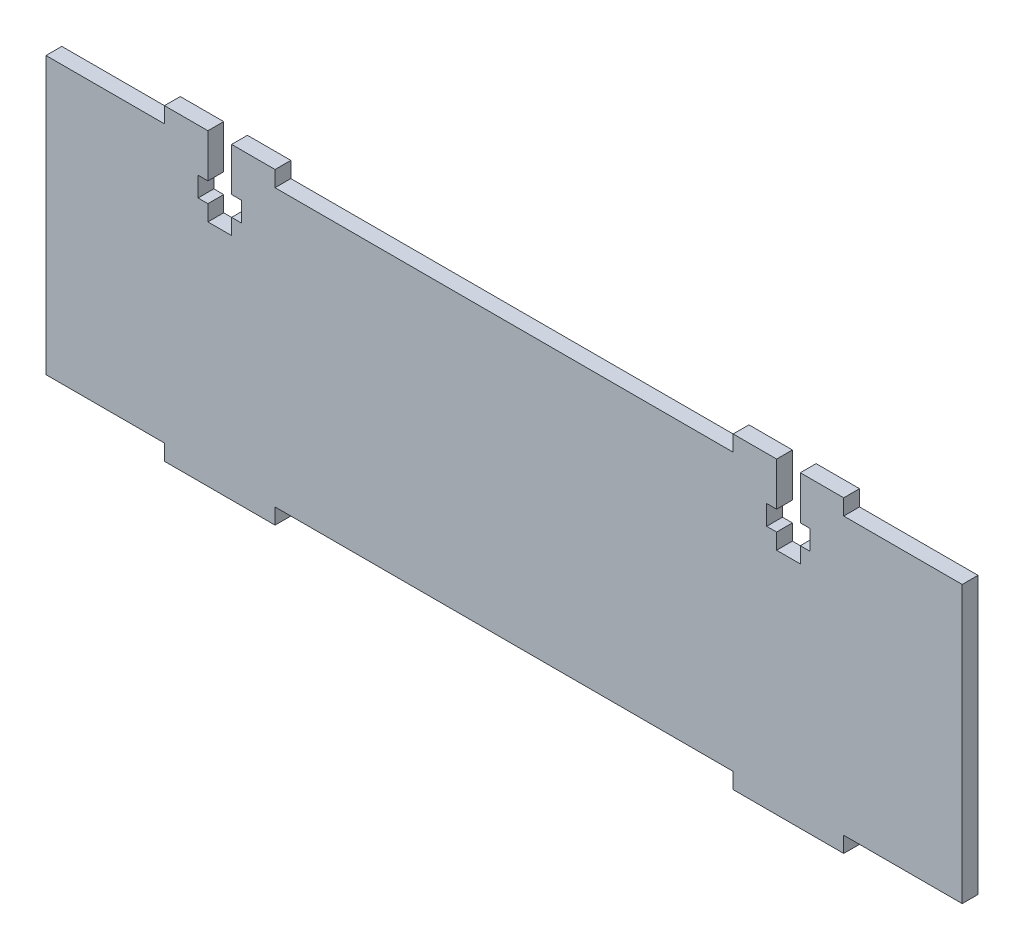
from build123d import *

# Parameters (mm, degrees)
MAIN_SLIDER_SIDE_DEPTH = 2


with BuildPart() as part:
    # Sketch1 → Main Slider Side (new body)
    with BuildSketch(Plane.XY):
        Polygon((0, 0), (15, 0), (15, -2), (29, -2), (29, 0), (87, 0), (87, -2), (101, -2), (101, 0), (116, 0), (116, 35), (101, 35), (101, 37), (95.5, 37), (95.5, 31.5), (96.75, 31.5), (96.75, 29), (95.5, 29), (95.5, 27), (92.5, 27), (92.5, 29), (91.25, 29), (91.25, 31.5), (92.5, 31.5), (92.5, 37), (87, 37), (87, 35), (29, 35), (29, 37), (23.5, 37), (23.5, 31.5), (24.75, 31.5), (24.75, 29), (23.5, 29), (23.5, 27), (20.5, 27), (20.5, 29), (19.25, 29), (19.25, 31.5), (20.5, 31.5), (20.5, 37), (15, 37), (15, 35), (0, 35), align=None)
    extrude(amount=MAIN_SLIDER_SIDE_DEPTH)


solid = part.part
